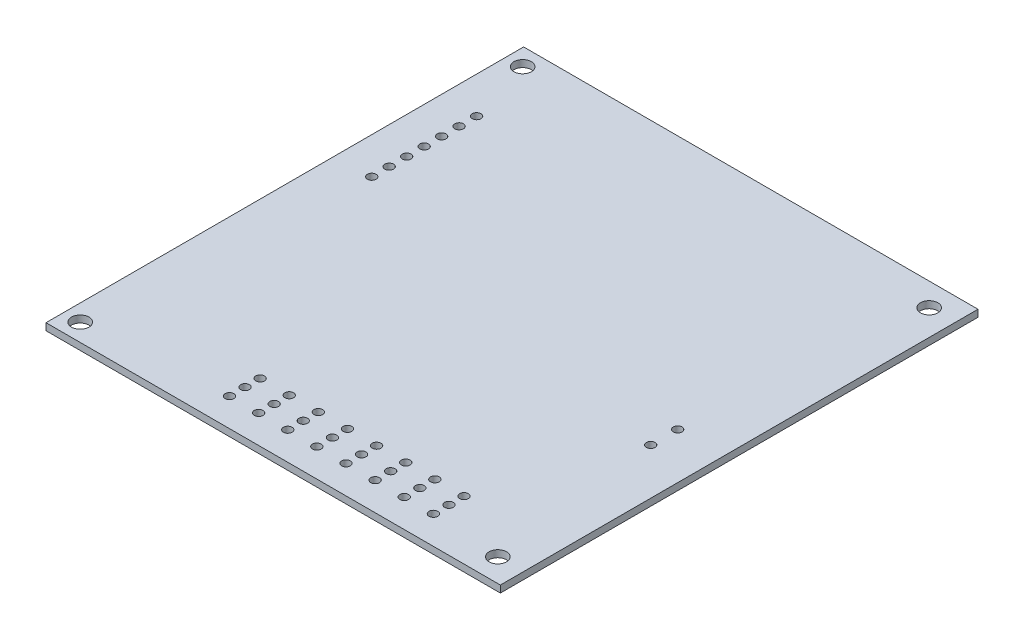
from build123d import *

# Parameters (mm, degrees)
SKETCH_1_W          = 78
SKETCH_1_H          = 82
EXTRUDE_1_DEPTH     = 1.2
SKETCH_2_R          = 1.5
CUT_EXTRUDE_1_DEPTH = 2.2
SKETCH_4_R          = 0.75
CUT_EXTRUDE_2_DEPTH = 2.2


with BuildPart() as part:
    # 草图1 → 凸台-拉伸1 (new body)
    with BuildSketch(Plane(origin=(0, 0, 0), x_dir=(1, 0, 0), z_dir=(0, 1, 0))):
        Rectangle(SKETCH_1_W, SKETCH_1_H)
    extrude(amount=EXTRUDE_1_DEPTH)

    # 草图2 → 切除-拉伸1 (cut, through all)
    with BuildSketch(Plane(origin=(0, 1.2, 0), x_dir=(1, 0, 0), z_dir=(0, 1, 0))):
        with Locations((34.589756088, 37.0205)):
            Circle(SKETCH_2_R)
        with Locations((34.589756088, -37.0205)):
            Circle(SKETCH_2_R)
        with Locations((-36.149243912, 37.973)):
            Circle(SKETCH_2_R)
        with Locations((-36.149243912, -37.973)):
            Circle(SKETCH_2_R)
    extrude(amount=-CUT_EXTRUDE_1_DEPTH, mode=Mode.SUBTRACT)

    # 草图4 → 切除-拉伸2 (cut, through all)
    with BuildSketch(Plane(origin=(0, 1.2, 0), x_dir=(1, 0, 0), z_dir=(0, 1, 0))):
        with Locations((31.088023819, -2.643707058)):
            Circle(SKETCH_4_R)
        with Locations((31.088023819, -7.274172682)):
            Circle(SKETCH_4_R)
        with Locations((-32.739432301, 26.660033395)):
            Circle(SKETCH_4_R)
        with Locations((22.666825283, -30.91162983)):
            Circle(SKETCH_4_R)
        with Locations((22.666825283, -33.492399097)):
            Circle(SKETCH_4_R)
        with Locations((22.666825283, -36.162160408)):
            Circle(SKETCH_4_R)
        with Locations((17.666825283, -36.162160408)):
            Circle(SKETCH_4_R)
        with Locations((17.666825283, -33.492399097)):
            Circle(SKETCH_4_R)
        with Locations((17.666825283, -30.91162983)):
            Circle(SKETCH_4_R)
        with Locations((12.666825283, -36.162160408)):
            Circle(SKETCH_4_R)
        with Locations((12.666825283, -33.492399097)):
            Circle(SKETCH_4_R)
        with Locations((12.666825283, -30.91162983)):
            Circle(SKETCH_4_R)
        with Locations((7.666825283, -36.162160408)):
            Circle(SKETCH_4_R)
        with Locations((7.666825283, -33.492399097)):
            Circle(SKETCH_4_R)
        with Locations((7.666825283, -30.91162983)):
            Circle(SKETCH_4_R)
        with Locations((2.666825283, -36.162160408)):
            Circle(SKETCH_4_R)
        with Locations((2.666825283, -33.492399097)):
            Circle(SKETCH_4_R)
        with Locations((2.666825283, -30.91162983)):
            Circle(SKETCH_4_R)
        with Locations((-2.333174717, -36.162160408)):
            Circle(SKETCH_4_R)
        with Locations((-2.333174717, -33.492399097)):
            Circle(SKETCH_4_R)
        with Locations((-2.333174717, -30.91162983)):
            Circle(SKETCH_4_R)
        with Locations((-7.333174717, -36.162160408)):
            Circle(SKETCH_4_R)
        with Locations((-7.333174717, -33.492399097)):
            Circle(SKETCH_4_R)
        with Locations((-7.333174717, -30.91162983)):
            Circle(SKETCH_4_R)
        with Locations((-12.333174717, -36.162160408)):
            Circle(SKETCH_4_R)
        with Locations((-12.333174717, -33.492399097)):
            Circle(SKETCH_4_R)
        with Locations((-12.333174717, -30.91162983)):
            Circle(SKETCH_4_R)
        with Locations((-32.739432301, 23.660033395)):
            Circle(SKETCH_4_R)
        with Locations((-32.739432301, 20.660033395)):
            Circle(SKETCH_4_R)
        with Locations((-32.739432301, 17.660033395)):
            Circle(SKETCH_4_R)
        with Locations((-32.739432301, 14.660033395)):
            Circle(SKETCH_4_R)
        with Locations((-32.739432301, 11.660033395)):
            Circle(SKETCH_4_R)
        with Locations((-32.739432301, 8.660033395)):
            Circle(SKETCH_4_R)
    extrude(amount=-CUT_EXTRUDE_2_DEPTH, mode=Mode.SUBTRACT)


solid = part.part
